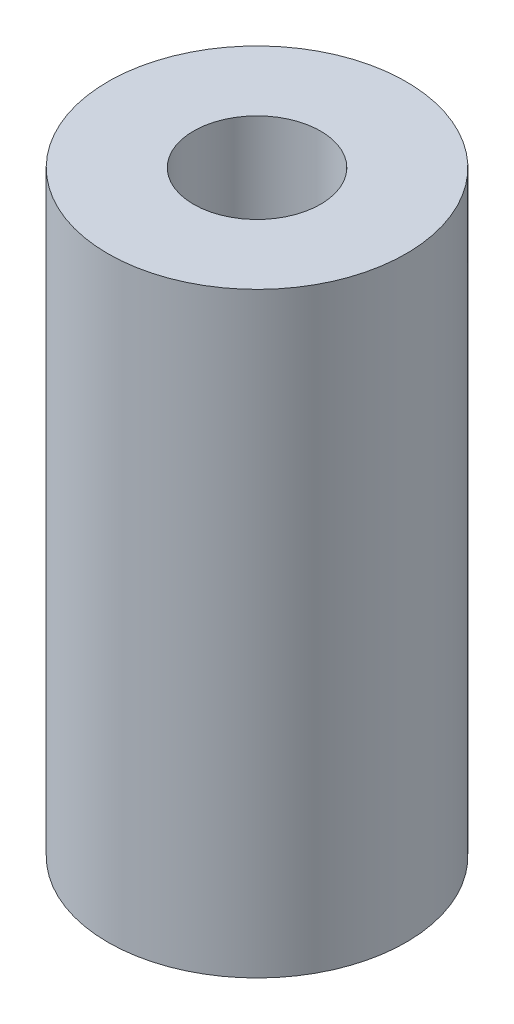
from build123d import *

# Parameters (mm, degrees)
SKETCH1_R                 = 3.175
BOSS_EXTRUDE1_DEPTH       = 12.7
TAP_DRILL_FOR_6_32_TAP1_D = 2.7051


with BuildPart() as part:
    # Sketch1 → Boss-Extrude1 (new body)
    with BuildSketch(Plane(origin=(0, 0, 0), x_dir=(1, 0, 0), z_dir=(0, 1, 0))):
        Circle(SKETCH1_R)
    extrude(amount=BOSS_EXTRUDE1_DEPTH)

    # Tap Drill for #6-32 Tap1 (through all)
    with Locations(Plane(origin=(0, 12.7, 0), x_dir=(1, 0, 0), z_dir=(0, 1, 0))):
        with Locations((0, 0)):
            Hole(TAP_DRILL_FOR_6_32_TAP1_D / 2)


solid = part.part
